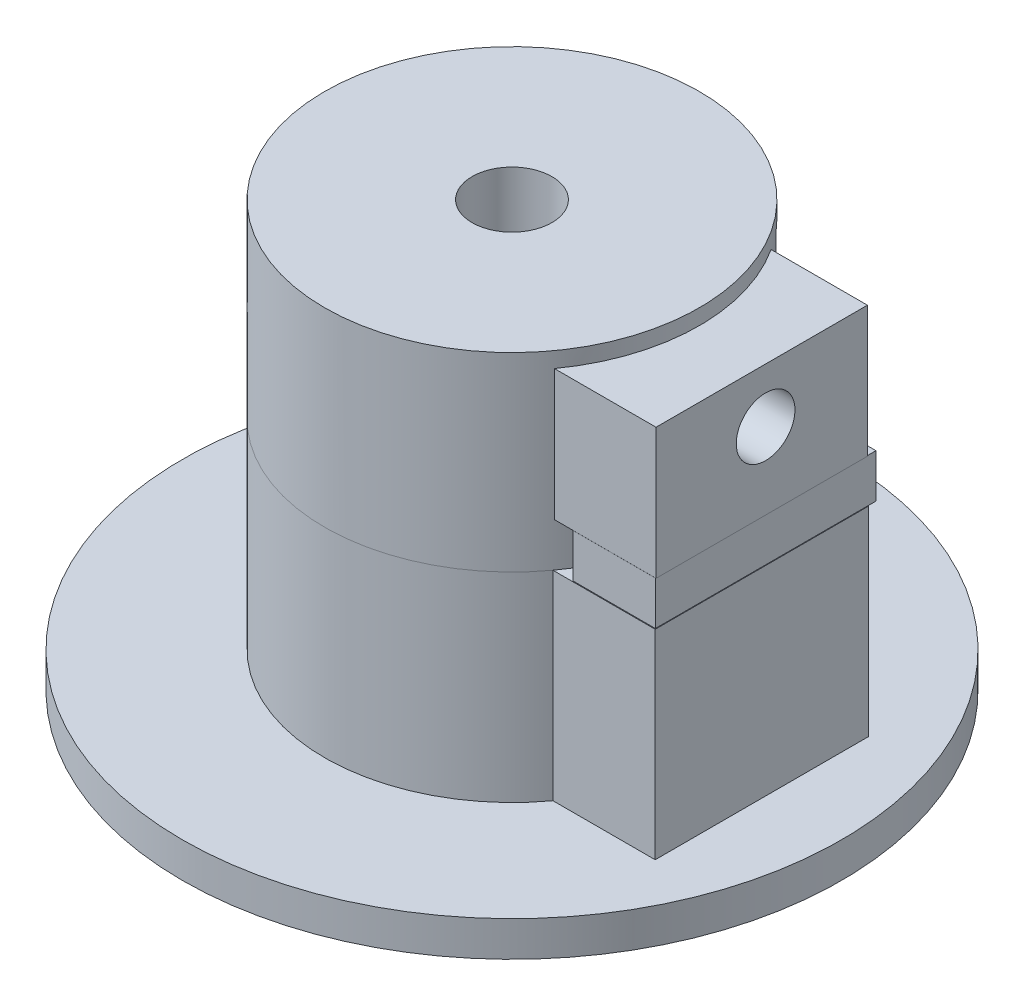
from build123d import *

# Parameters (mm, degrees)
SKETCH1_R                                      = 15.958
SHAFTHOLDERNEARMOTOR_DEPTH                     = 17.19
SKETCH2_R                                      = 3.4
SHAFTHOLE_DEPTH                                = 16.85
SKETCH5_W                                      = 1.550685087
SKETCH5_H                                      = 7.184215806
BOSS_EXTRUDE2_DEPTH                            = 13.55
SKETCH7_W                                      = 18.003976239
SKETCH7_H                                      = 11.144937805
BOSS_EXTRUDE3_DEPTH                            = 19
SKETCH6_R                                      = 2.5
BOLTHOLE_DEPTH                                 = 1
BOLTHOLE_DEPTH_BACK                            = 19
SKETCH10_R                                     = 50
BOSS_EXTRUDE4_DEPTH                            = 20
SKETCH12_R                                     = 43
SKETCH12_R_2                                   = 15.95790089
CUTTOREMVEEXCESSMATERIAL_DEPTH                 = 17
SKETCH13_R                                     = 50
SKETCH13_R_2                                   = 42.696683681
BOSS_EXTRUDE5_DEPTH                            = 17
SKETCH9_W                                      = 7.462346342
SKETCH9_H                                      = 9.19456217
NUTOPENING_DEPTH                               = 74.484692283
HEXCUT_DEPTH                                   = 7.462346343
SKETCH16_R                                     = 6
CUT_EXTRUDE7_DEPTH                             = 40
SKETCH19_R                                     = 12
CUT_EXTRUDE8_DEPTH                             = 5
SKETCH20_R                                     = 12
CUT_EXTRUDE9_DEPTH                             = 5
SKETCH22_R                                     = 12.553525499
CUT_EXTRUDE10_DEPTH                            = 5
SKETCH21_R                                     = 10
CUT_EXTRUDE11_DEPTH                            = 5
SKETCH23_R                                     = 11.965333231
CUT_EXTRUDE12_DEPTH                            = 5
SKETCH25_R                                     = 9.629681042
CUT_EXTRUDE13_DEPTH                            = 5
SKETCH26_R                                     = 15.012411299
CUT_EXTRUDE14_DEPTH                            = 5
SKETCH27_R                                     = 11.854712092
CUT_EXTRUDE15_DEPTH                            = 5
SKETCH28_W                                     = 8.838679887
SKETCH28_H                                     = 18.172415452
BOSS_EXTRUDE6_DEPTH                            = 17
SKETCH29_W                                     = 7.025540803
SKETCH29_H                                     = 18.786067296
BOSS_EXTRUDE7_DEPTH                            = 3.722722351
SKETCH31_R                                     = 26.336547497
CUT_EXTRUDE16_DEPTH                            = 1
SKETCH32_R                                     = 3.380332453
CUT_EXTRUDE17_DEPTH                            = 2
SKETCH33_R                                     = 63.32413164
SKETCH33_R_2                                   = 28.068575678
REMOVEOUTSIDEOFWHEEL_WOULDLIKETODISABLET_DEPTH = 80.806015003
CUTOUTWEDGETOMAKEBOTINSERTIONEASIER_DEPTH      = 7.462346


with BuildPart() as part:
    # Sketch1 → ShaftHolderNearMotor (new body)
    with BuildSketch(Plane(origin=(0, 0, 0), x_dir=(1, 0, 0), z_dir=(0, 1, 0))):
        with Locations(Location((0, 0, 0), (0, 0, 270))):
            Circle(SKETCH1_R)
    extrude(amount=SHAFTHOLDERNEARMOTOR_DEPTH)

    # Sketch2 → ShaftHole (cut)
    with BuildSketch(Plane(origin=(0, 17.19, 0), x_dir=(1, 0, 0), z_dir=(0, 1, 0))):
        with Locations(Location((0, 0, 0), (0, 0, 270))):
            Circle(SKETCH2_R)
    extrude(amount=-SHAFTHOLE_DEPTH, mode=Mode.SUBTRACT)

    # Sketch5 → Boss-Extrude2 (add)
    with BuildSketch(Plane(origin=(0, 12.15, 0), x_dir=(1, 0, 0), z_dir=(0, 1, 0))):
        with Locations((3.375342544, 0.020519704)):
            Rectangle(SKETCH5_W, SKETCH5_H)
    extrude(amount=-BOSS_EXTRUDE2_DEPTH)

    # Sketch7 → Boss-Extrude3 (add)
    with BuildSketch(Plane.ZY.offset(-2.6)):
        with Locations((0.33027221, 9.295191254)):
            Rectangle(SKETCH7_W, SKETCH7_H)
    extrude(amount=-BOSS_EXTRUDE3_DEPTH)

    # Sketch6 → BoltHole (cut, two sides)
    with BuildSketch(Plane.ZY.offset(-2.6)) as bolthole_sk:
        with Locations(Location((0, 10.236925537, 0), (0, 0, 208.794122803))):
            Circle(SKETCH6_R)
    extrude(amount=BOLTHOLE_DEPTH, mode=Mode.SUBTRACT)
    extrude(bolthole_sk.sketch, amount=-BOLTHOLE_DEPTH_BACK, mode=Mode.SUBTRACT)

    # Sketch10 → Boss-Extrude4 (add)
    with BuildSketch(Plane.XZ):
        with Locations(Location((0, 0, 0), (0, 0, 270))):
            Circle(SKETCH10_R)
    extrude(amount=BOSS_EXTRUDE4_DEPTH)

    # Sketch12 → CutToRemveExcessMaterial (cut)
    with BuildSketch(Plane(origin=(0, 0, 0), x_dir=(1, 0, 0), z_dir=(0, 1, 0))):
        with Locations(Location((0, 0, 0), (0, 0, 270))):
            Circle(SKETCH12_R)
        with Locations(Location((0, 0, 0), (0, 0, 270))):
            Circle(SKETCH12_R_2, mode=Mode.SUBTRACT)
    extrude(amount=-CUTTOREMVEEXCESSMATERIAL_DEPTH, mode=Mode.SUBTRACT)

    # Sketch13 → Boss-Extrude5 (add)
    with BuildSketch(Plane(origin=(0, 0, 0), x_dir=(1, 0, 0), z_dir=(0, 1, 0))):
        with Locations(Location((0, 0, 0), (0, 0, 270))):
            Circle(SKETCH13_R)
        with Locations(Location((0, 0, 0), (0, 0, 270))):
            Circle(SKETCH13_R_2, mode=Mode.SUBTRACT)
    extrude(amount=BOSS_EXTRUDE5_DEPTH)

    # Sketch9 → NutOpening (cut, through all)
    with BuildSketch(Plane.XY):
        with Locations((8.408039956, 10.202052717)):
            Rectangle(SKETCH9_W, SKETCH9_H)
    extrude(amount=-NUTOPENING_DEPTH, mode=Mode.SUBTRACT)

    # Sketch14 → HexCut (cut)
    with BuildSketch(Plane.ZY.offset(-12.139213127)):
        Polygon((-5.320810683, 10.236925537), (-2.660405341, 5.628968317), (2.660405341, 5.628968317), (5.320810683, 10.236925537), (2.660405341, 14.844882757), (-2.660405341, 14.844882757), align=None)
    extrude(amount=HEXCUT_DEPTH, mode=Mode.SUBTRACT)

    # Sketch16 → Cut-Extrude7 (cut)
    with BuildSketch(Plane(origin=(21.6, 0, 0), x_dir=(0, 0, -1), z_dir=(1, 0, 0))):
        with Locations(Location((0, 10.236925537, 0), (0, 0, 180))):
            Circle(SKETCH16_R)
    extrude(amount=CUT_EXTRUDE7_DEPTH, mode=Mode.SUBTRACT)

    # Sketch19 → Cut-Extrude8 (cut)
    with BuildSketch(Plane(origin=(9.351145186, 0, 49.117777675), x_dir=(0.9823555534957298, 0, -0.18702290372063646), z_dir=(0.18702290372063649, 0, 0.9823555534957299))):
        with Locations((-6.553798813, -15.044376388)):
            Circle(SKETCH19_R)
    extrude(amount=-CUT_EXTRUDE8_DEPTH, mode=Mode.SUBTRACT)

    # Sketch20 → Cut-Extrude9 (cut)
    with BuildSketch(Plane(origin=(35.756785301, 0, 34.949281894), x_dir=(0.6989856378867483, 0, -0.7151357060223296), z_dir=(0.7151357060223296, 0, 0.6989856378867483))):
        with Locations((3.558365894, 19.429208609)):
            Circle(SKETCH20_R)
    extrude(amount=-CUT_EXTRUDE9_DEPTH, mode=Mode.SUBTRACT)

    # Sketch22 → Cut-Extrude10 (cut)
    with BuildSketch(Plane(origin=(34.949281894, 0, -35.756785301), x_dir=(-0.7151357060223288, 0, -0.698985637886749), z_dir=(0.698985637886749, 0, -0.7151357060223288))):
        with Locations((5.427738333, 18.490794011)):
            Circle(SKETCH22_R)
    extrude(amount=-CUT_EXTRUDE10_DEPTH, mode=Mode.SUBTRACT)

    # Sketch21 → Cut-Extrude11 (cut)
    with BuildSketch(Plane(origin=(49.117777675, 0, -9.351145186), x_dir=(-0.18702290372063798, 0, -0.9823555534957294), z_dir=(0.9823555534957294, 0, -0.18702290372063798))):
        with Locations((-4.791175632, -19.221882877)):
            Circle(SKETCH21_R)
    extrude(amount=-CUT_EXTRUDE11_DEPTH, mode=Mode.SUBTRACT)

    # Sketch23 → Cut-Extrude12 (cut)
    with BuildSketch(Plane(origin=(-0.570991135, 0, -49.996739585), x_dir=(-0.9999347916987428, 0, 0.011419822695298289), z_dir=(-0.011419822695298287, 0, -0.9999347916987427))):
        with Locations((4.525183767, -20.017770037)):
            Circle(SKETCH23_R)
    extrude(amount=-CUT_EXTRUDE12_DEPTH, mode=Mode.SUBTRACT)

    # Sketch25 → Cut-Extrude13 (cut)
    with BuildSketch(Plane(origin=(-41.343771844, 0, -28.119255498), x_dir=(-0.5623851099550343, 0, 0.8268754368711554), z_dir=(-0.8268754368711554, 0, -0.5623851099550343))):
        with Locations((-2.649823638, 18.643158668)):
            Circle(SKETCH25_R)
    extrude(amount=-CUT_EXTRUDE13_DEPTH, mode=Mode.SUBTRACT)

    # Sketch26 → Cut-Extrude14 (cut)
    with BuildSketch(Plane(origin=(-49.117777675, 0, 9.351145186), x_dir=(0.18702290372063635, 0, 0.9823555534957298), z_dir=(-0.9823555534957298, 0, 0.18702290372063635))):
        with Locations((-4.497650602, -19.126376963)):
            Circle(SKETCH26_R)
    extrude(amount=-CUT_EXTRUDE14_DEPTH, mode=Mode.SUBTRACT)

    # Sketch27 → Cut-Extrude15 (cut)
    with BuildSketch(Plane(origin=(-28.119255498, 0, 41.343771844), x_dir=(0.8268754368711555, 0, 0.562385109955034), z_dir=(-0.562385109955034, 0, 0.8268754368711555))):
        with Locations((-2.287517393, 17.62218093)):
            Circle(SKETCH27_R)
    extrude(amount=-CUT_EXTRUDE15_DEPTH, mode=Mode.SUBTRACT)

    # Sketch28 → Boss-Extrude6 (add)
    with BuildSketch(Plane.XZ):
        with Locations((17.180660057, 0.317955018)):
            Rectangle(SKETCH28_W, SKETCH28_H)
    extrude(amount=BOSS_EXTRUDE6_DEPTH)

    # Sketch29 → Boss-Extrude7 (add)
    with BuildSketch(Plane.XZ.offset(-3.722722351)):
        with Locations((18.03590553, -0.055280695)):
            Rectangle(SKETCH29_W, SKETCH29_H)
    extrude(amount=BOSS_EXTRUDE7_DEPTH)

    # Sketch31 → Cut-Extrude16 (cut)
    with BuildSketch(Plane(origin=(0, 17.19, 0), x_dir=(1, 0, 0), z_dir=(0, 1, 0))):
        Circle(SKETCH31_R)
    extrude(amount=-CUT_EXTRUDE16_DEPTH, mode=Mode.SUBTRACT)

    # Sketch32 → Cut-Extrude17 (cut)
    with BuildSketch(Plane(origin=(0, 14.867660156, 0), x_dir=(1, 0, 0), z_dir=(0, 1, 0))):
        Circle(SKETCH32_R)
    extrude(amount=-CUT_EXTRUDE17_DEPTH, mode=Mode.SUBTRACT)

    # Sketch33 → RemoveOutsideOfWheel_WouldLikeToDisableT (cut, through all)
    with BuildSketch(Plane.XZ.offset(20)):
        Circle(SKETCH33_R)
        with Locations(Location((0, 0, 0), (0, 0, 270))):
            Circle(SKETCH33_R_2, mode=Mode.SUBTRACT)
    extrude(amount=-REMOVEOUTSIDEOFWHEEL_WOULDLIKETODISABLET_DEPTH, mode=Mode.SUBTRACT)

    # Sketch37 → CutOutWedgeToMakeBotInsertionEasier (cut)
    with BuildSketch(Plane(origin=(4.676866785, 0, 0), x_dir=(0, 0, -1), z_dir=(1, 0, 0))):
        Polygon((15.257282886, 5.604771632), (14.323551181, 3.368491211), (5.921663956, 5.604771632), align=None)
    extrude(amount=CUTOUTWEDGETOMAKEBOTINSERTIONEASIER_DEPTH, mode=Mode.SUBTRACT)


solid = part.part
